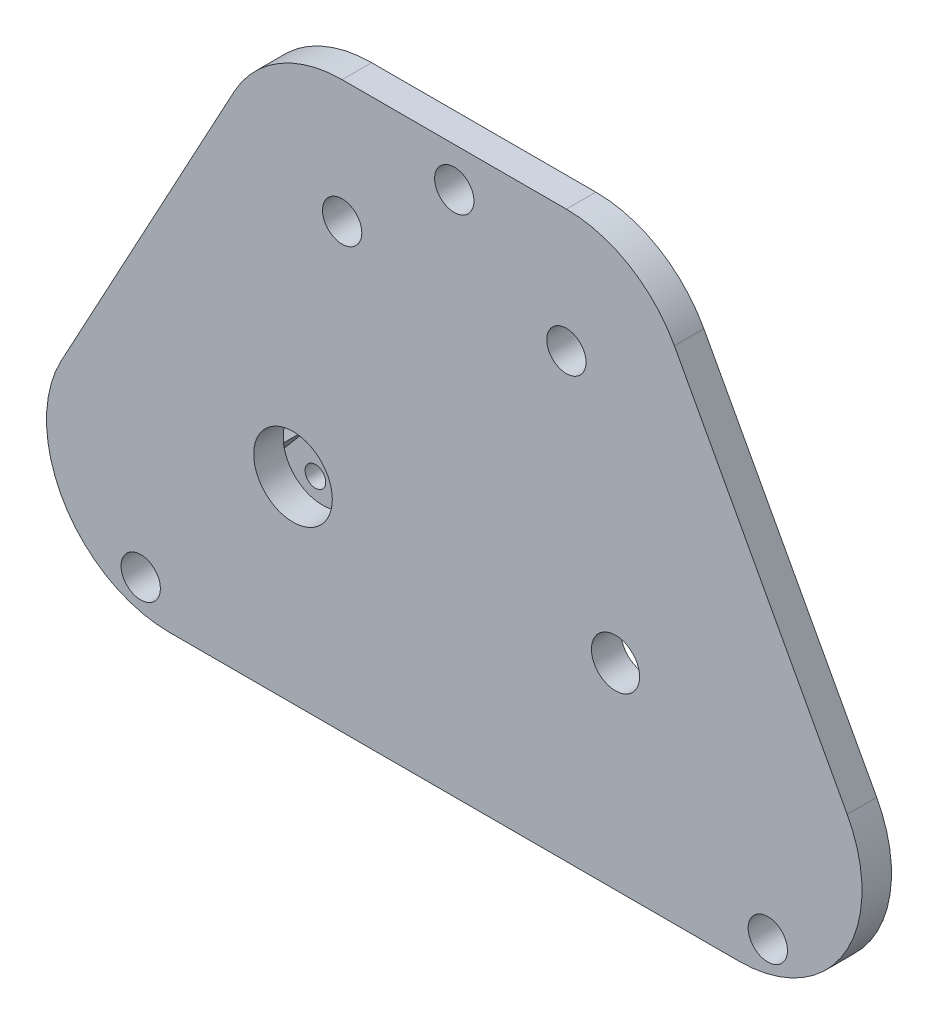
from build123d import *

# Parameters (mm, degrees)
SKETCH1_R           = 4
SKETCH1_R_2         = 2.45
SKETCH1_R_3         = 2
BOSS_EXTRUDE1_DEPTH = 3
SKETCH2_R           = 1.05
BOSS_EXTRUDE2_DEPTH = 8.3
SKETCH2_3_R         = 1.05
CUT_EXTRUDE1_DEPTH  = 5


with BuildPart() as part:
    # Sketch1 → Boss-Extrude1 (new body)
    with BuildSketch(Plane.XY):
        with BuildLine():
            ThreePointArc((-11.41, 37.5), (-17.8088531, 35.73800163), (-22.403743203, 30.948748641))
            Line((-22.403743203, 30.948748641), (-39.989594287, -1.551251359))
            ThreePointArc((-39.989594287, -1.551251359), (-39.733852714, -13.8988531), (-28.995851084, -20))
            Line((-28.995851084, -20), (28.995851084, -20))
            ThreePointArc((28.995851084, -20), (39.733852714, -13.8988531), (39.989594287, -1.551251359))
            Line((39.989594287, -1.551251359), (22.403743203, 30.948748641))
            ThreePointArc((22.403743203, 30.948748641), (17.8088531, 35.73800163), (11.41, 37.5))
            Line((11.41, 37.5), (-11.41, 37.5))
        make_face()
        with Locations((-16.41, 0)):
            Circle(SKETCH1_R, mode=Mode.SUBTRACT)
        with Locations((16.41, 0)):
            Circle(SKETCH1_R_2, mode=Mode.SUBTRACT)
        with Locations((-11.41, 25)):
            Circle(SKETCH1_R_3, mode=Mode.SUBTRACT)
        with Locations((11.41, 25)):
            Circle(SKETCH1_R_3, mode=Mode.SUBTRACT)
        with Locations((0, 33.5)):
            Circle(SKETCH1_R_3, mode=Mode.SUBTRACT)
        with Locations((31.91, -16.6)):
            Circle(SKETCH1_R_3, mode=Mode.SUBTRACT)
        with Locations((-31.91, -16.6)):
            Circle(SKETCH1_R_3, mode=Mode.SUBTRACT)
    extrude(amount=BOSS_EXTRUDE1_DEPTH)

    # Sketch2 → Boss-Extrude2 (add)
    # profile 1 of 2: a face of its own
    with BuildSketch(Plane(origin=(0, 0, 0), x_dir=(-1, 0, 0), z_dir=(0, 0, -1))):
        Polygon((-2.088967553, 12.478509505), (1.060691735, 8.724891734), (10.483038385, 16.631179333), (7.333379097, 20.384797104), align=None)
        with Locations((4.004199133, 14.784657752)):
            Circle(SKETCH2_R, mode=Mode.SUBTRACT)
    # profile 2 of 2: a face of its own
    with BuildSketch(Plane(origin=(0, 0, 0), x_dir=(-1, 0, 0), z_dir=(0, 0, -1))):
        Polygon((15.651970474, -8.664317125), (18.801629762, -12.417934896), (28.223976412, -4.511647297), (25.074317125, -0.758029526), align=None)
        with Locations((22.130809726, -6.817795544)):
            Circle(SKETCH2_R, mode=Mode.SUBTRACT)
    extrude(amount=BOSS_EXTRUDE2_DEPTH)

    # Sketch2_3 → Cut-Extrude1 (cut)
    # profile 1 of 2: a face of its own
    with BuildSketch(Plane(origin=(0, 0, 0), x_dir=(-1, 0, 0), z_dir=(0, 0, -1))):
        Polygon((0.324072443, 14.503290476), (3.47373173, 10.749672705), (8.069998389, 14.606398363), (4.920339102, 18.360016134), align=None)
        with Locations((4.004199133, 14.784657752)):
            Circle(SKETCH2_3_R, mode=Mode.SUBTRACT)
    # profile 2 of 2: a face of its own
    with BuildSketch(Plane(origin=(0, 0, 0), x_dir=(-1, 0, 0), z_dir=(0, 0, -1))):
        Polygon((22.661277129, -2.782810496), (18.06501047, -6.639536154), (21.214669758, -10.393153926), (25.810936416, -6.536428267), align=None)
        with Locations((22.130809726, -6.817795544)):
            Circle(SKETCH2_3_R, mode=Mode.SUBTRACT)
    extrude(amount=CUT_EXTRUDE1_DEPTH, mode=Mode.SUBTRACT)


solid = part.part
